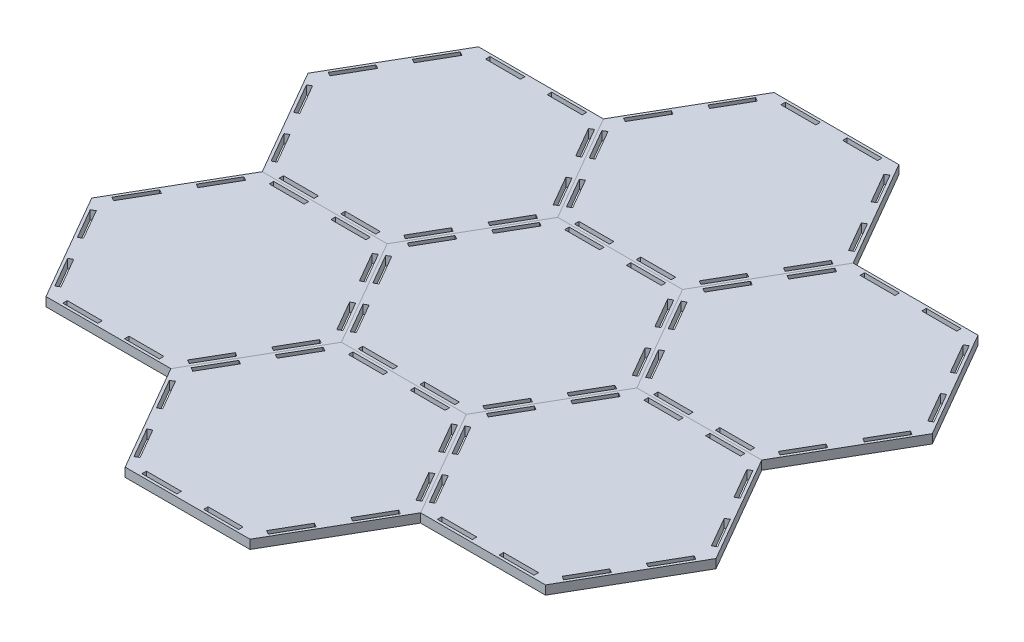
from build123d import *

# Parameters (mm, degrees)
BOSS_EXTRUDE1_DEPTH = 6.35
SKETCH2_W           = 24.892
SKETCH2_H           = 3.175
CUT_EXTRUDE1_DEPTH  = 118.774954893
CIRPATTERN1_COUNT   = 6


with BuildPart() as part:
    # Sketch1 → Boss-Extrude1 (new body)
    with BuildSketch(Plane(origin=(0, 0, 0), x_dir=(1, 0, 0), z_dir=(0, 1, 0))):
        Polygon((-88.9, 0), (-44.45, -76.989658396), (44.45, -76.989658396), (88.9, 0), (44.45, 76.989658396), (-44.45, 76.989658396), align=None)
    extrude(amount=BOSS_EXTRUDE1_DEPTH)

    # Sketch2 → Cut-Extrude1 (cut, through all)
    with BuildSketch(Plane(origin=(0, 6.35, 0), x_dir=(1, 0, 0), z_dir=(0, 1, 0))):
        Polygon((-79.484090949, -6.148832876), (-82.233721606, -7.736332876), (-69.787721606, -29.293437227), (-67.038090949, -27.705937227), align=None)
        Polygon((-45.067090949, -65.76082552), (-47.816721606, -67.34832552), (-60.262721606, -45.791221169), (-57.513090949, -44.203721169), align=None)
        Polygon((-45.067090949, 65.76082552), (-47.816721606, 67.34832552), (-60.262721606, 45.791221169), (-57.513090949, 44.203721169), align=None)
        Polygon((-69.787721606, 29.293437227), (-67.038090949, 27.705937227), (-79.484090949, 6.148832876), (-82.233721606, 7.736332876), align=None)
        with Locations((21.971, 73.497158396)):
            Rectangle(SKETCH2_W, SKETCH2_H)
        with Locations((-21.971, 73.497158396)):
            Rectangle(SKETCH2_W, SKETCH2_H)
        Polygon((79.484090949, 6.148832876), (82.233721606, 7.736332876), (69.787721606, 29.293437227), (67.038090949, 27.705937227), align=None)
        Polygon((60.262721606, 45.791221169), (57.513090949, 44.203721169), (45.067090949, 65.76082552), (47.816721606, 67.34832552), align=None)
        Polygon((45.067090949, -65.76082552), (47.816721606, -67.34832552), (60.262721606, -45.791221169), (57.513090949, -44.203721169), align=None)
        Polygon((69.787721606, -29.293437227), (67.038090949, -27.705937227), (79.484090949, -6.148832876), (82.233721606, -7.736332876), align=None)
        with Locations((-21.971, -73.497158396)):
            Rectangle(SKETCH2_W, SKETCH2_H)
        with Locations((21.971, -73.497158396)):
            Rectangle(SKETCH2_W, SKETCH2_H)
    extrude(amount=-CUT_EXTRUDE1_DEPTH, mode=Mode.SUBTRACT)


with BuildPart() as body_2:
    # Mirror1: mirrored copy
    add(part.part.mirror(Plane(origin=(44.45, 6.35, 76.989658396), x_dir=(-0.5000000000000006, 0, 0.8660254037844384), z_dir=(-0.8660254037844385, 0, -0.5000000000000004))))


with BuildPart() as cirpattern1_1:
    # CirPattern1: pattern copy
    add(body_2.part.rotate(Axis((0, 0, 0), (0, 1, 0)), 1 * 360 / CIRPATTERN1_COUNT))


with BuildPart() as cirpattern1_2:
    # CirPattern1: pattern copy
    add(body_2.part.rotate(Axis((0, 0, 0), (0, 1, 0)), 2 * 360 / CIRPATTERN1_COUNT))


with BuildPart() as cirpattern1_3:
    # CirPattern1: pattern copy
    add(body_2.part.rotate(Axis((0, 0, 0), (0, 1, 0)), 3 * 360 / CIRPATTERN1_COUNT))


with BuildPart() as cirpattern1_4:
    # CirPattern1: pattern copy
    add(body_2.part.rotate(Axis((0, 0, 0), (0, 1, 0)), 4 * 360 / CIRPATTERN1_COUNT))


with BuildPart() as cirpattern1_5:
    # CirPattern1: pattern copy
    add(body_2.part.rotate(Axis((0, 0, 0), (0, 1, 0)), 5 * 360 / CIRPATTERN1_COUNT))


solid = Compound([part.part, body_2.part, cirpattern1_1.part, cirpattern1_2.part, cirpattern1_3.part, cirpattern1_4.part, cirpattern1_5.part])
